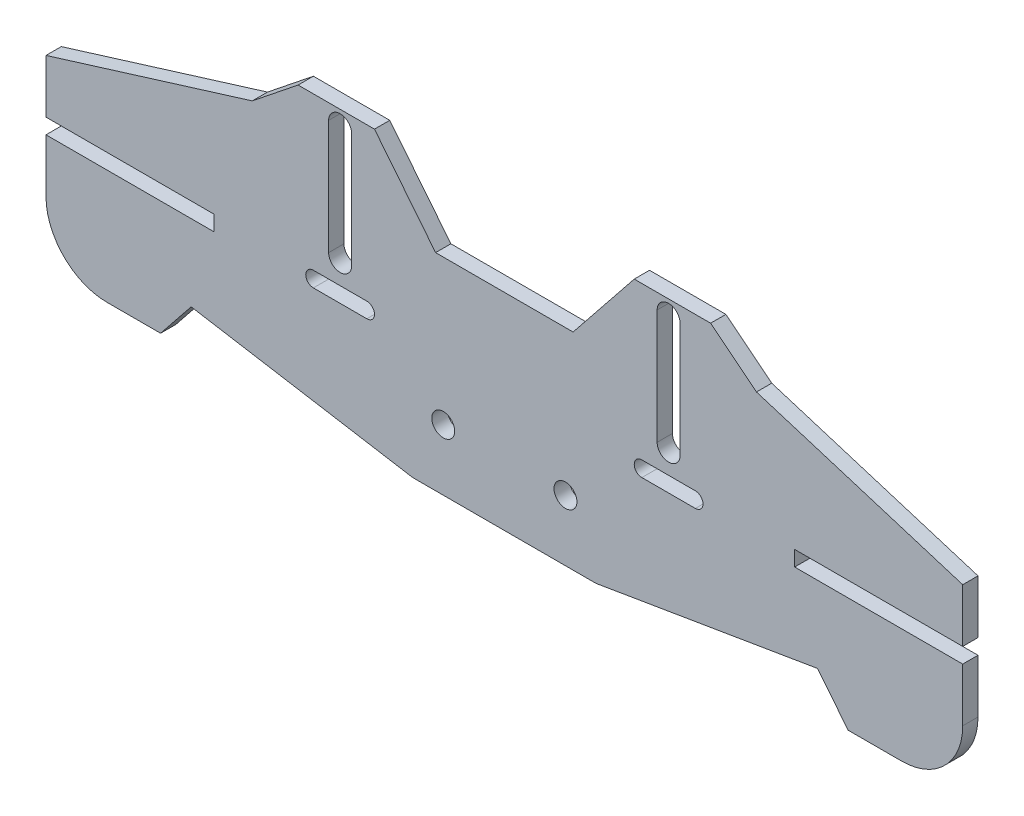
from build123d import *

# Parameters (mm, degrees)
RESSALTO_EXTRUS_O1_DEPTH = 2
ESBO_O2_R                = 1.5
ESBO_O2_W                = 22
ESBO_O2_H                = 2
CORTE_EXTRUS_O1_DEPTH    = 3


with BuildPart() as part:
    # Esboço1 → Ressalto-extrusão1 (new body)
    with BuildSketch(Plane.XY):
        with BuildLine():
            Line((52, -0.143401487), (45, -0.143401487))
            Line((45, -0.143401487), (41, 4.856598513))
            Line((41, 4.856598513), (12, 0))
            Line((12, 0), (0, 0))
            Line((0, 0), (0, 27))
            Line((0, 27), (9, 27))
            Line((9, 27), (17, 37))
            Line((17, 37), (27, 37))
            Line((27, 37), (33, 32.2))
            Line((33, 32.2), (60, 23.856598513))
            Line((60, 23.856598513), (60, 7.856598513))
            ThreePointArc((60, 7.856598513), (57.656854249, 2.199744264), (52, -0.143401487))
        make_face()
    ressalto_extrus_o1 = extrude(amount=RESSALTO_EXTRUS_O1_DEPTH)

    # Espelhar1: Ressalto-extrusão1 across plane
    add(ressalto_extrus_o1.mirror(Plane(origin=(0, 0, 0), x_dir=(0, 0, 1), z_dir=(1, 0, 0))))

    # Esboço2 → Corte-extrusão1 (cut, through all)
    with BuildSketch(Plane.XY.offset(2)):
        with Locations((8, 8)):
            Circle(ESBO_O2_R)
        with Locations((-8, 8)):
            Circle(ESBO_O2_R)
        with Locations((49, 15.856598513)):
            Rectangle(ESBO_O2_W, ESBO_O2_H)
        with BuildLine():
            Line((23, 35), (23, 20))
            ThreePointArc((23, 20), (21.5, 18.5), (20, 20))
            Line((20, 20), (20, 35))
            ThreePointArc((20, 35), (21.5, 36.5), (23, 35))
        make_face()
        with BuildLine():
            Line((25, 15), (18, 15))
            ThreePointArc((18, 15), (17, 16), (18, 17))
            Line((18, 17), (25, 17))
            ThreePointArc((25, 17), (26, 16), (25, 15))
        make_face()
        with BuildLine():
            Line((-23, 35), (-23, 20))
            ThreePointArc((-23, 20), (-21.5, 18.5), (-20, 20))
            Line((-20, 20), (-20, 35))
            ThreePointArc((-20, 35), (-21.5, 36.5), (-23, 35))
        make_face()
        with BuildLine():
            Line((-25, 15), (-18, 15))
            ThreePointArc((-18, 15), (-17, 16), (-18, 17))
            Line((-18, 17), (-25, 17))
            ThreePointArc((-25, 17), (-26, 16), (-25, 15))
        make_face()
        with Locations((-49, 15.856598513)):
            Rectangle(ESBO_O2_W, ESBO_O2_H)
    extrude(amount=-CORTE_EXTRUS_O1_DEPTH, mode=Mode.SUBTRACT)


solid = part.part
